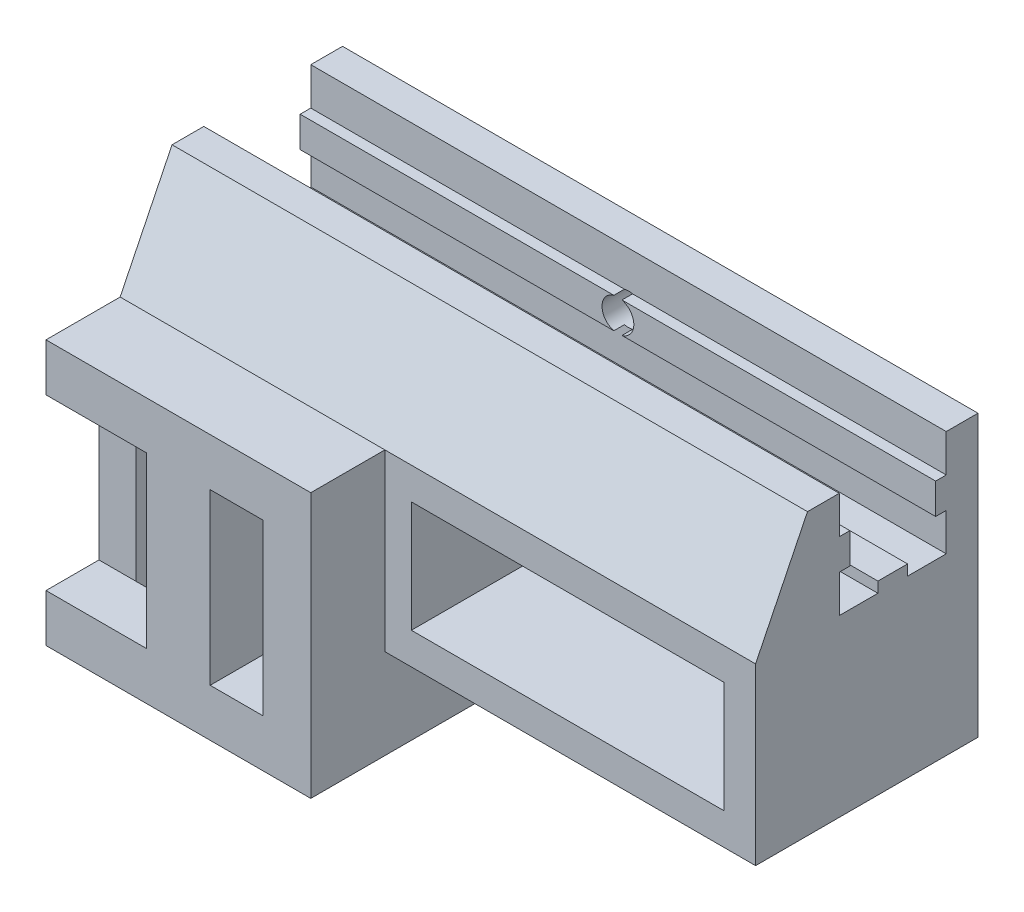
from build123d import *

# Parameters (mm, degrees)
ESQUISSE1_W                    = 60
ESQUISSE1_H                    = 35
MAIN_DEPTH                     = 3
ESQUISSE2_W                    = 60
ESQUISSE2_H                    = 2.9
HORIZONTALMAKERBEAMRAIL1_DEPTH = 1
ESQUISSE3_R                    = 1.5
VERTICALFIXHOLE_DEPTH          = 5
ESQUISSE4_W                    = 25
ESQUISSE4_H                    = 25
ESQUISSE4_W_2                  = 18
ESQUISSE4_H_2                  = 18
URGENCYBUTTON_DEPTH            = 20
ESQUISSE5_W                    = 18
ESQUISSE5_H                    = 18
URGENCYBUTTONHOLE_DEPTH        = 1
URGENCYBUTTONHOLE_DEPTH_BACK   = 24
BOSS_EXTRU_4_DEPTH             = 5
ESQUISSE7_W                    = 6
ESQUISSE7_H                    = 25
BOSS_EXTRU_5_DEPTH             = 5
ESQUISSE8_W                    = 29.5
ESQUISSE8_H                    = 10.5
SWITCHHOLE_DEPTH               = 29
ESQUISSE10_W                   = 35
ESQUISSE10_H                   = 16.5
ESQUISSE10_W_2                 = 29.5
ESQUISSE10_H_2                 = 10.5
BOSS_EXTRU_6_DEPTH             = 18
ESQUISSE11_W                   = 35
ESQUISSE11_H                   = 8.5
ENL_V_MAT_EXTRU_4_DEPTH        = 4
ESQUISSE12_W                   = 60
ESQUISSE12_H                   = 2.8
BOSS_EXTRU_7_DEPTH             = 1
BOSS_EXTRU_8_DEPTH             = 60
BOSS_EXTRU_9_DEPTH             = 60


with BuildPart() as part:
    # Esquisse1 → Main (new body)
    with BuildSketch(Plane.XY):
        Rectangle(ESQUISSE1_W, ESQUISSE1_H)
    extrude(amount=MAIN_DEPTH)

    # Esquisse2 → HorizontalMakerBeamRail1 (add)
    with BuildSketch(Plane.XY.offset(3)):
        with Locations((0, 12.5)):
            Rectangle(ESQUISSE2_W, ESQUISSE2_H)
    extrude(amount=HORIZONTALMAKERBEAMRAIL1_DEPTH)

    # Esquisse3 → VerticalFixHole (cut, through all)
    with BuildSketch(Plane(origin=(0, 0, 0), x_dir=(-1, 0, 0), z_dir=(0, 0, -1))):
        with Locations((0, 12.5)):
            Circle(ESQUISSE3_R)
    extrude(amount=-VERTICALFIXHOLE_DEPTH, mode=Mode.SUBTRACT)

    # Esquisse4 → UrgencyButton (add)
    with BuildSketch(Plane.XY.offset(3)):
        with Locations((-17.5, -5)):
            Rectangle(ESQUISSE4_W, ESQUISSE4_H)
        with Locations((-17.5, -5)):
            Rectangle(ESQUISSE4_W_2, ESQUISSE4_H_2, mode=Mode.SUBTRACT)
    extrude(amount=URGENCYBUTTON_DEPTH)

    # Esquisse5 → UrgencyButtonHole (cut, two sides)
    with BuildSketch(Plane.XY.offset(23)) as urgencybuttonhole_sk:
        with Locations((-17.5, -5)):
            Rectangle(ESQUISSE5_W, ESQUISSE5_H)
    extrude(amount=URGENCYBUTTONHOLE_DEPTH, mode=Mode.SUBTRACT)
    extrude(urgencybuttonhole_sk.sketch, amount=-URGENCYBUTTONHOLE_DEPTH_BACK, mode=Mode.SUBTRACT)

    # Esquisse6 → Boss.-Extru.4 (add)
    with BuildSketch(Plane.XY.offset(23)):
        Polygon((-30, -17.5), (-5, -17.5), (-5, 7.5), (-30, 7.5), (-30, 3), (-9.5, 3), (-9.5, -13), (-30, -13), align=None)
    extrude(amount=BOSS_EXTRU_4_DEPTH)

    # Esquisse7 → Boss.-Extru.5 (add)
    with BuildSketch(Plane.XY.offset(28)):
        with Locations((-17.5, -5)):
            Rectangle(ESQUISSE7_W, ESQUISSE7_H)
    extrude(amount=-BOSS_EXTRU_5_DEPTH)

    # Esquisse8 → SwitchHole (cut, through all)
    with BuildSketch(Plane(origin=(0, 0, 0), x_dir=(-1, 0, 0), z_dir=(0, 0, -1))):
        with Locations((-12.25, -0.75)):
            Rectangle(ESQUISSE8_W, ESQUISSE8_H)
    extrude(amount=-SWITCHHOLE_DEPTH, mode=Mode.SUBTRACT)

    # Esquisse10 → Boss.-Extru.6 (add)
    with BuildSketch(Plane.XY.offset(3)):
        with Locations((12.5, -0.75)):
            Rectangle(ESQUISSE10_W, ESQUISSE10_H)
        with Locations((12.25, -0.75)):
            Rectangle(ESQUISSE10_W_2, ESQUISSE10_H_2, mode=Mode.SUBTRACT)
    extrude(amount=BOSS_EXTRU_6_DEPTH)

    # Esquisse11 → Enlèv. mat.-Extru.4 (cut, through all)
    with BuildSketch(Plane.XY.offset(3)):
        with Locations((12.5, -13.25)):
            Rectangle(ESQUISSE11_W, ESQUISSE11_H)
    extrude(amount=-ENL_V_MAT_EXTRU_4_DEPTH, mode=Mode.SUBTRACT)

    # Esquisse12 → Boss.-Extru.7 (add)
    with BuildSketch(Plane(origin=(0, 7.5, 0), x_dir=(1, 0, 0), z_dir=(0, 1, 0))):
        with Locations((0, -8.05)):
            Rectangle(ESQUISSE12_W, ESQUISSE12_H)
    extrude(amount=BOSS_EXTRU_7_DEPTH)

    # Esquisse13 → Boss.-Extru.8 (add, through all)
    with BuildSketch(Plane(origin=(30, 0, 0), x_dir=(0, 0, -1), z_dir=(1, 0, 0))):
        Polygon((-13.1, 7.5), (-13.1, 11.05), (-12.1, 11.05), (-12.1, 13.95), (-13.1, 13.95), (-13.1, 17.5), (-16.1, 17.5), (-16.1, 7.5), align=None)
    extrude(amount=-BOSS_EXTRU_8_DEPTH)

    # Esquisse14 → Boss.-Extru.9 (add, through all)
    with BuildSketch(Plane(origin=(30, 0, 0), x_dir=(0, 0, -1), z_dir=(1, 0, 0))):
        Polygon((-16.1, 7.5), (-16.1, 17.5), (-21, 7.5), align=None)
    extrude(amount=-BOSS_EXTRU_9_DEPTH)


solid = part.part
